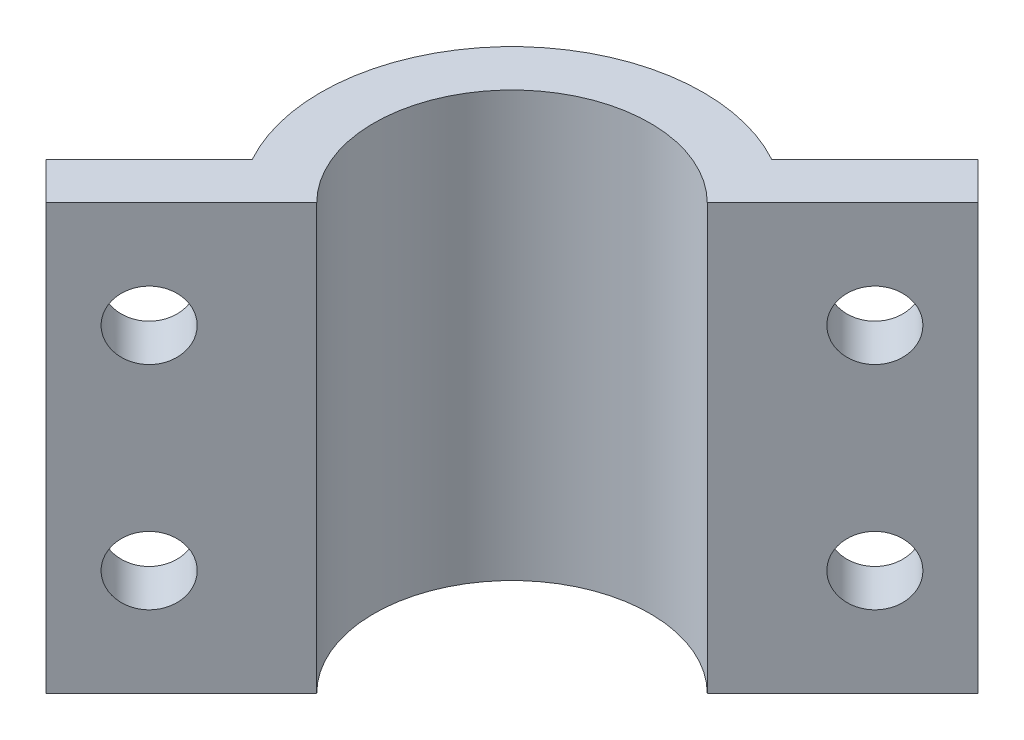
from build123d import *

# Parameters (mm, degrees)
BOSS_EXTRUDE1_DEPTH      = 1.5
M3_CLEARANCE_HOLE1_D     = 3.2
M3_CLEARANCE_HOLE1_DEPTH = 3
SKETCH5_R                = 15
CUT_EXTRUDE1_DEPTH       = 1
CUT_EXTRUDE1_DEPTH_BACK  = 4
SKETCH6_R                = 13
BOSS_EXTRUDE2_DEPTH      = 40
M6_CLEARANCE_HOLE1_D     = 6.4
M6_CLEARANCE_HOLE1_DEPTH = 10
SKETCH11_OUTSIDE_W       = 233.632
SKETCH11_OUTSIDE_H       = 233.632
CUT_EXTRUDE2_DEPTH       = 40
SKETCH12_W               = 183.089507272
SKETCH12_H               = 5.144734847
CUT_EXTRUDE4_DEPTH       = 91
CUT_EXTRUDE4_DEPTH_BACK  = 91


with BuildPart() as part:
    # Sketch1 → Boss-Extrude1 (new body, symmetric)
    with BuildSketch(Plane(origin=(0, 0, 0), x_dir=(1, 0, 0), z_dir=(0, 1, 0))):
        with BuildLine():
            Line((50, 10), (84, 10))
            ThreePointArc((84, 10), (88.242640687, 8.242640687), (90, 4))
            Line((90, 4), (90, -4))
            ThreePointArc((90, -4), (88.242640687, -8.242640687), (84, -10))
            Line((84, -10), (50, -10))
            ThreePointArc((50, -10), (21.715728753, -21.715728753), (10, -50))
            Line((10, -50), (10, -84))
            ThreePointArc((10, -84), (8.242640687, -88.242640687), (4, -90))
            Line((4, -90), (-4, -90))
            ThreePointArc((-4, -90), (-8.242640687, -88.242640687), (-10, -84))
            Line((-10, -84), (-10, -50))
            ThreePointArc((-10, -50), (-21.715728753, -21.715728753), (-50, -10))
            Line((-50, -10), (-84, -10))
            ThreePointArc((-84, -10), (-88.242640687, -8.242640687), (-90, -4))
            Line((-90, -4), (-90, 4))
            ThreePointArc((-90, 4), (-88.242640687, 8.242640687), (-84, 10))
            Line((-84, 10), (-50, 10))
            ThreePointArc((-50, 10), (-21.715728753, 21.715728753), (-10, 50))
            Line((-10, 50), (-10, 84))
            ThreePointArc((-10, 84), (-8.242640687, 88.242640687), (-4, 90))
            Line((-4, 90), (4, 90))
            ThreePointArc((4, 90), (8.242640687, 88.242640687), (10, 84))
            Line((10, 84), (10, 50))
            ThreePointArc((10, 50), (21.715728753, 21.715728753), (50, 10))
        make_face()
    extrude(amount=BOSS_EXTRUDE1_DEPTH, both=True)

    # M3 Clearance Hole1
    with Locations(Plane(origin=(0, 1.5, 0), x_dir=(1, 0, 0), z_dir=(0, 1, 0))):
        with Locations((-84, 4), (-84, -4), (-4, 84), (4, 84), (84, 4), (84, -4), (4, -84), (-4, -84), (-39, 4), (-39, -4), (39, 4), (39, -4), (4, -39), (-4, -39), (-4, 39), (4, 39)):
            Hole(M3_CLEARANCE_HOLE1_D / 2, depth=M3_CLEARANCE_HOLE1_DEPTH)

    # Sketch5 → Cut-Extrude1 (cut, two sides)
    with BuildSketch(Plane(origin=(0, 1.5, 0), x_dir=(1, 0, 0), z_dir=(0, 1, 0))) as cut_extrude1_sk:
        Circle(SKETCH5_R)
    extrude(amount=CUT_EXTRUDE1_DEPTH, mode=Mode.SUBTRACT)
    extrude(cut_extrude1_sk.sketch, amount=-CUT_EXTRUDE1_DEPTH_BACK, mode=Mode.SUBTRACT)

    # Sketch6 → Boss-Extrude2 (add)
    with BuildSketch(Plane.XZ.offset(1.5)):
        with BuildLine():
            Line((-15.762553167, 8.691485355), (-25.473103505, 18.402035693))
            Line((-25.473103505, 18.402035693), (-18.402035693, 25.473103505))
            Line((-18.402035693, 25.473103505), (-8.691485355, 15.762553167))
            ThreePointArc((-8.691485355, 15.762553167), (12.727922061, 12.727922061), (15.762553167, -8.691485355))
            Line((15.762553167, -8.691485355), (25.473103505, -18.402035693))
            Line((25.473103505, -18.402035693), (18.402035693, -25.473103505))
            Line((18.402035693, -25.473103505), (8.691485355, -15.762553167))
            ThreePointArc((8.691485355, -15.762553167), (-12.727922061, -12.727922061), (-15.762553167, 8.691485355))
        make_face()
        Circle(SKETCH6_R, mode=Mode.SUBTRACT)
    extrude(amount=BOSS_EXTRUDE2_DEPTH)

    # M6 Clearance Hole1
    with Locations(Plane(origin=(3.535533906, 0, 3.535533906), x_dir=(0.707106781, 0, -0.707106781), z_dir=(0.707106781, 0, 0.707106781))):
        with Locations((-24.158012459, -11.5), (-24.158012459, -31.5), (24.158012459, -11.5), (24.158012459, -31.5)):
            Hole(M6_CLEARANCE_HOLE1_D / 2, depth=M6_CLEARANCE_HOLE1_DEPTH)

    # Sketch11 outside → Cut-Extrude2 (cut)
    with BuildSketch(Plane.XZ.offset(41.5)):
        Rectangle(SKETCH11_OUTSIDE_W, SKETCH11_OUTSIDE_H)
        with BuildLine():
            Line((-21.937569599, 21.937569599), (21.937569599, -21.937569599))
            Line((21.937569599, -21.937569599), (18.402035693, -25.473103505))
            Line((18.402035693, -25.473103505), (8.691485355, -15.762553167))
            ThreePointArc((8.691485355, -15.762553167), (-12.727922061, -12.727922061), (-15.762553167, 8.691485355))
            Line((-15.762553167, 8.691485355), (-25.473103505, 18.402035693))
            Line((-25.473103505, 18.402035693), (-21.937569599, 21.937569599))
        make_face(mode=Mode.SUBTRACT)
    extrude(amount=-CUT_EXTRUDE2_DEPTH, mode=Mode.SUBTRACT)

    # Sketch12 → Cut-Extrude4 (cut, two sides)
    with BuildSketch(Plane(origin=(0, 0, 0), x_dir=(0, 0, -1), z_dir=(1, 0, 0))) as cut_extrude4_sk:
        with Locations((-1.544753636, 1.072367424)):
            Rectangle(SKETCH12_W, SKETCH12_H)
    extrude(amount=CUT_EXTRUDE4_DEPTH, mode=Mode.SUBTRACT)
    extrude(cut_extrude4_sk.sketch, amount=-CUT_EXTRUDE4_DEPTH_BACK, mode=Mode.SUBTRACT)


solid = part.part
